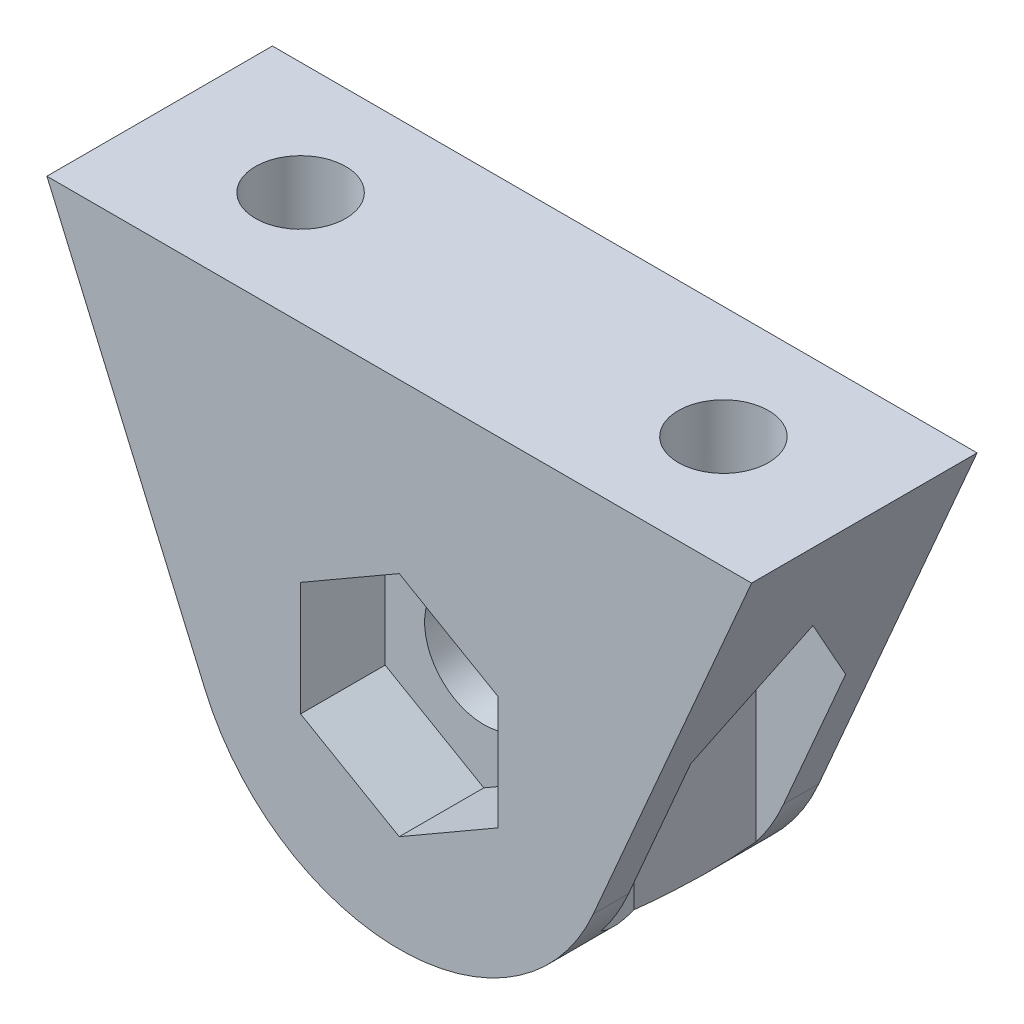
from build123d import *

# Parameters (mm, degrees)
SKETCH1_R           = 2.1
BOSS_EXTRUDE1_DEPTH = 8
SKETCH2_R           = 1.6
CUT_EXTRUDE1_DEPTH  = 18.5
CUT_EXTRUDE2_DEPTH  = 3
CUT_EXTRUDE3_START  = -3
CUT_EXTRUDE3_DEPTH  = 15.5000001


with BuildPart() as part:
    # Sketch1 → Boss-Extrude1 (new body)
    with BuildSketch(Plane.XY):
        with BuildLine():
            Line((-6.883064085, -2.978830106), (-12.5, 10))
            Line((-12.5, 10), (12.5, 10))
            Line((12.5, 10), (6.883064085, -2.978830106))
            ThreePointArc((6.883064085, -2.978830106), (0, -7.5), (-6.883064085, -2.978830106))
        make_face()
        Circle(SKETCH1_R, mode=Mode.SUBTRACT)
    extrude(amount=BOSS_EXTRUDE1_DEPTH)

    # Sketch2 → Cut-Extrude1 (cut, through all)
    with BuildSketch(Plane(origin=(0, 10, 0), x_dir=(1, 0, 0), z_dir=(0, 1, 0))):
        with Locations((-7.5, -4)):
            Circle(SKETCH2_R)
        with Locations((7.5, -4)):
            Circle(SKETCH2_R)
    extrude(amount=-CUT_EXTRUDE1_DEPTH, mode=Mode.SUBTRACT)

    # Sketch3 → Cut-Extrude2 (cut)
    with BuildSketch(Plane.XY.offset(8)):
        Polygon((0, -4.041451884), (3.5, -2.020725942), (3.5, 2.020725942), (0, 4.041451884), (-3.5, 2.020725942), (-3.5, -2.020725942), align=None)
    extrude(amount=-CUT_EXTRUDE2_DEPTH, mode=Mode.SUBTRACT)

    # Sketch4 → Cut-Extrude3 (cut, through all)
    with BuildSketch(Plane(origin=(0, 10, 0), x_dir=(1, 0, 0), z_dir=(0, 1, 0)).offset(CUT_EXTRUDE3_START)):
        Polygon((-5.91228676, -6.75), (-4.324573519, -4), (-5.91228676, -1.25), (-9.08771324, -1.25), (-10.675426481, -4), (-9.08771324, -6.75), align=None)
        Polygon((9.08771324, -6.75), (5.91228676, -6.75), (4.324573519, -4), (5.91228676, -1.25), (9.08771324, -1.25), (10.675426481, -4), align=None)
    extrude(amount=-CUT_EXTRUDE3_DEPTH, mode=Mode.SUBTRACT)


solid = part.part
